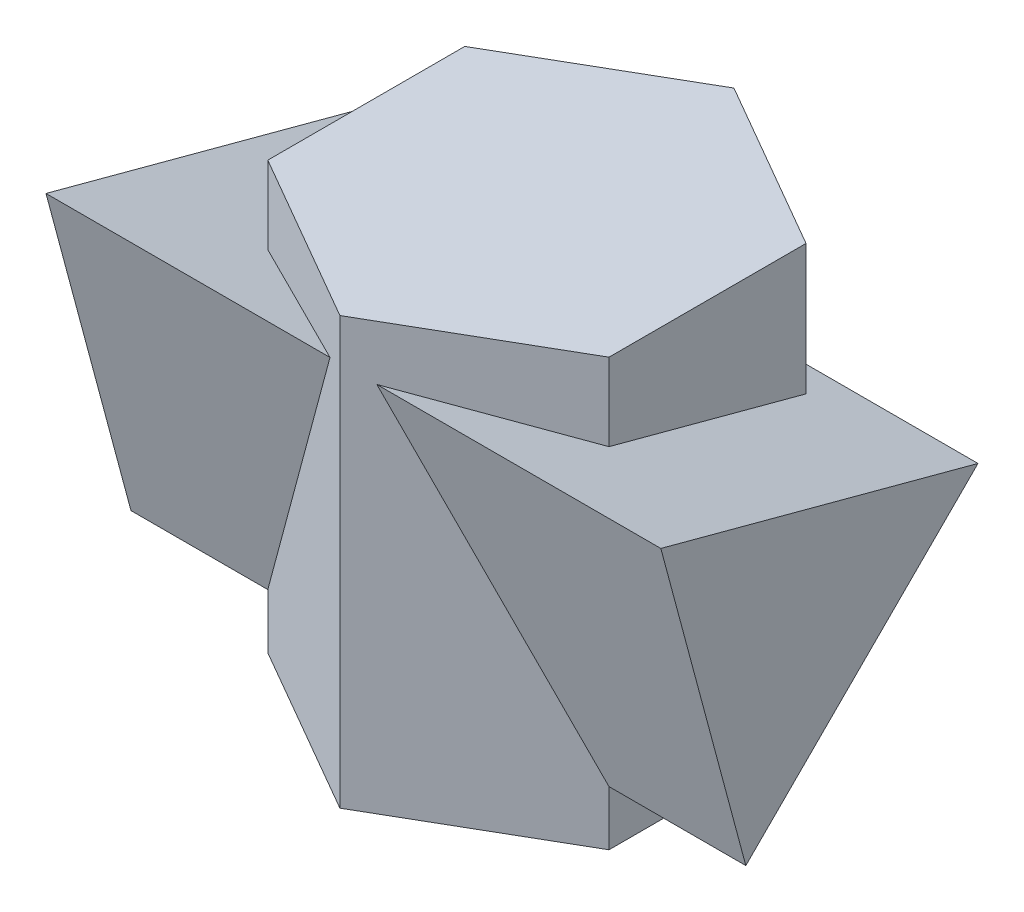
from build123d import *

# Parameters (mm, degrees)
EXTRUDE1_DEPTH = 77.96
EXTRUDE2_DEPTH = 56.175


with BuildPart() as part:
    # Sketch3 → Extrude1 (new body)
    with BuildSketch(Plane(origin=(0, 0, 0), x_dir=(1, 0, 0), z_dir=(0, 1, 0))):
        Polygon((0, 54), (-31.176914536, 36), (-31.176914536, 0), (0, -18), (31.176914536, 0), (31.176914536, 36), align=None)
    extrude(amount=EXTRUDE1_DEPTH)

    # Sketch2 → Extrude2 (add, symmetric)
    with BuildSketch(Plane(origin=(0, 0, 0), x_dir=(0, 0, -1), z_dir=(1, 0, 0))):
        Polygon((0, 10), (42.426406871, 52.426406871), (-15.529142706, 67.955549577), align=None)
    extrude(amount=EXTRUDE2_DEPTH, both=True)


solid = part.part
